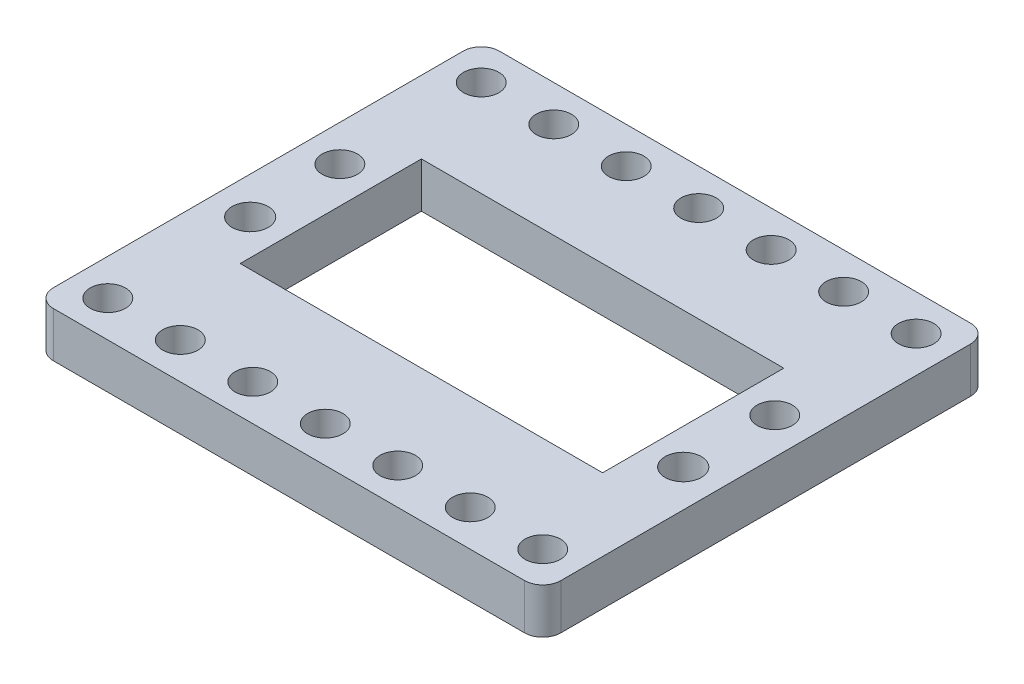
from build123d import *

# Parameters (mm, degrees)
BOSS_EXTRUDE1_DEPTH = 5
SKETCH2_R           = 1.95
SKETCH2_W           = 40
SKETCH2_H           = 20
CUT_EXTRUDE1_DEPTH  = 6
SKETCH4_W           = 22
SKETCH4_H           = 49.22
CUT_EXTRUDE2_DEPTH  = 10
FILLET1_R           = 2
FILLET2_R           = 2
FILLET3_R           = 2
FILLET4_R           = 2
SKETCH5_R           = 1.95
SKETCH5_R_2         = 2
CUT_EXTRUDE3_DEPTH  = 6


with BuildPart() as part:
    # Sketch1 → Boss-Extrude1 (new body)
    with BuildSketch(Plane(origin=(0, 0, 0), x_dir=(1, 0, 0), z_dir=(0, 1, 0))):
        with BuildLine():
            Line((2, 0), (98, 0))
            ThreePointArc((98, 0), (99.414213562, -0.585786438), (100, -2))
            Line((100, -2), (100, -47.22))
            ThreePointArc((100, -47.22), (99.414213562, -48.634213562), (98, -49.22))
            Line((98, -49.22), (2, -49.22))
            ThreePointArc((2, -49.22), (0.585786438, -48.634213562), (0, -47.22))
            Line((0, -47.22), (0, -2))
            ThreePointArc((0, -2), (0.585786438, -0.585786438), (2, 0))
        make_face()
    extrude(amount=BOSS_EXTRUDE1_DEPTH)

    # Sketch2 → Cut-Extrude1 (cut, through all)
    with BuildSketch(Plane(origin=(0, 5, 0), x_dir=(1, 0, 0), z_dir=(0, 1, 0))):
        with Locations((90, -4.00475022)):
            Circle(SKETCH2_R)
        with Locations((82, -4.00475022)):
            Circle(SKETCH2_R)
        with Locations((18, -4.00475022)):
            Circle(SKETCH2_R)
        with Locations((26, -4.00475022)):
            Circle(SKETCH2_R)
        with Locations((34, -4.00475022)):
            Circle(SKETCH2_R)
        with Locations((42, -4.00475022)):
            Circle(SKETCH2_R)
        with Locations((50, -4.00475022)):
            Circle(SKETCH2_R)
        with Locations((58, -4.00475022)):
            Circle(SKETCH2_R)
        with Locations((66, -4.00475022)):
            Circle(SKETCH2_R)
        with Locations((74, -4.00475022)):
            Circle(SKETCH2_R)
        with Locations((90, -45.22)):
            Circle(SKETCH2_R)
        with Locations((82, -45.22)):
            Circle(SKETCH2_R)
        with Locations((18, -45.22)):
            Circle(SKETCH2_R)
        with Locations((26, -45.22)):
            Circle(SKETCH2_R)
        with Locations((34, -45.22)):
            Circle(SKETCH2_R)
        with Locations((42, -45.22)):
            Circle(SKETCH2_R)
        with Locations((50, -45.22)):
            Circle(SKETCH2_R)
        with Locations((58, -45.22)):
            Circle(SKETCH2_R)
        with Locations((66, -45.22)):
            Circle(SKETCH2_R)
        with Locations((74, -45.22)):
            Circle(SKETCH2_R)
        with Locations((50, -24.61)):
            Rectangle(SKETCH2_W, SKETCH2_H)
    extrude(amount=-CUT_EXTRUDE1_DEPTH, mode=Mode.SUBTRACT)

    # Sketch4 → Cut-Extrude2 (cut)
    with BuildSketch(Plane(origin=(0, 5, 0), x_dir=(1, 0, 0), z_dir=(0, 1, 0))):
        with Locations((89, -24.61)):
            Rectangle(SKETCH4_W, SKETCH4_H)
        with Locations((11, -24.61)):
            Rectangle(SKETCH4_W, SKETCH4_H)
    extrude(amount=-CUT_EXTRUDE2_DEPTH, mode=Mode.SUBTRACT)

    # Fillet1
    fillet1_edges = [part.edges().sort_by_distance(p)[0] for p in [
        (22, 2.5, 0),
    ]]
    fillet(fillet1_edges, radius=FILLET1_R)

    # Fillet2
    fillet2_edges = [part.edges().sort_by_distance(p)[0] for p in [
        (22, 2.5, 49.22),
    ]]
    fillet(fillet2_edges, radius=FILLET2_R)

    # Fillet3
    fillet3_edges = [part.edges().sort_by_distance(p)[0] for p in [
        (78, 2.5, 49.22),
    ]]
    fillet(fillet3_edges, radius=FILLET3_R)

    # Fillet4
    fillet4_edges = [part.edges().sort_by_distance(p)[0] for p in [
        (78, 2.5, 0),
    ]]
    fillet(fillet4_edges, radius=FILLET4_R)

    # Sketch5 → Cut-Extrude3 (cut, through all)
    with BuildSketch(Plane(origin=(0, 5, 0), x_dir=(1, 0, 0), z_dir=(0, 1, 0))):
        with Locations((74, -19.610250006)):
            Circle(SKETCH5_R)
        with Locations((73.9, -29.609749994)):
            Circle(SKETCH5_R_2)
        with Locations((26, -19.610250006)):
            Circle(SKETCH5_R)
        with Locations((26.1, -29.609749994)):
            Circle(SKETCH5_R_2)
    extrude(amount=-CUT_EXTRUDE3_DEPTH, mode=Mode.SUBTRACT)


solid = part.part
